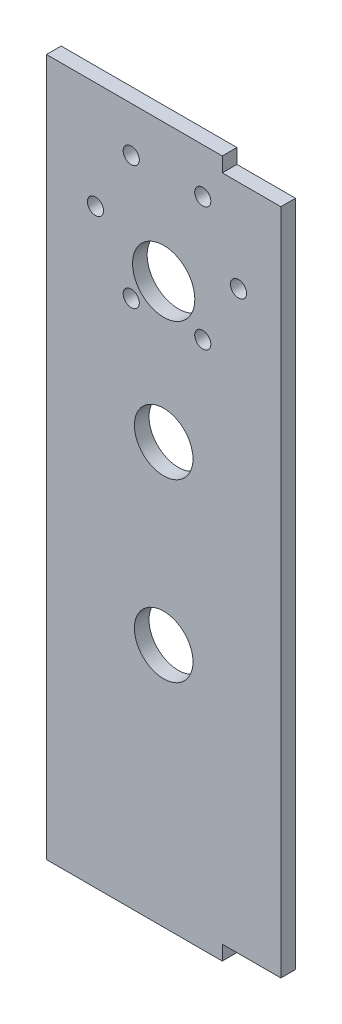
from build123d import *

# Parameters (mm, degrees)
SKETCH_1_R      = 6.75
SKETCH_1_R_2    = 1.75
SKETCH_1_R_3    = 6.35
EXTRUDE_1_DEPTH = 3.175


with BuildPart() as part:
    # Эскиз1 → Бобышка-Вытянуть1 (new body)
    with BuildSketch(Plane.XY):
        Polygon((19.05, 151.13), (-19.05, 151.13), (-19.05, 0), (19.05, 0), (19.05, 3.175), (31.75, 3.175), (31.75, 147.955), (19.05, 147.955), align=None)
        with Locations((6.35, 121.243303121)):
            Circle(SKETCH_1_R, mode=Mode.SUBTRACT)
        with Locations((22.568070331, 127.955)):
            Circle(SKETCH_1_R_2, mode=Mode.SUBTRACT)
        with Locations((14.818070331, 114.531606241)):
            Circle(SKETCH_1_R_2, mode=Mode.SUBTRACT)
        with Locations((-0.681929669, 114.531606241)):
            Circle(SKETCH_1_R_2, mode=Mode.SUBTRACT)
        with Locations((-8.431929669, 127.955)):
            Circle(SKETCH_1_R_2, mode=Mode.SUBTRACT)
        with Locations((-0.681929669, 141.378393759)):
            Circle(SKETCH_1_R_2, mode=Mode.SUBTRACT)
        with Locations((14.818070331, 141.378393759)):
            Circle(SKETCH_1_R_2, mode=Mode.SUBTRACT)
        with Locations((6.35, 91.080803121)):
            Circle(SKETCH_1_R_3, mode=Mode.SUBTRACT)
        with Locations((6.35, 52.980803121)):
            Circle(SKETCH_1_R_3, mode=Mode.SUBTRACT)
    extrude(amount=EXTRUDE_1_DEPTH)


solid = part.part
